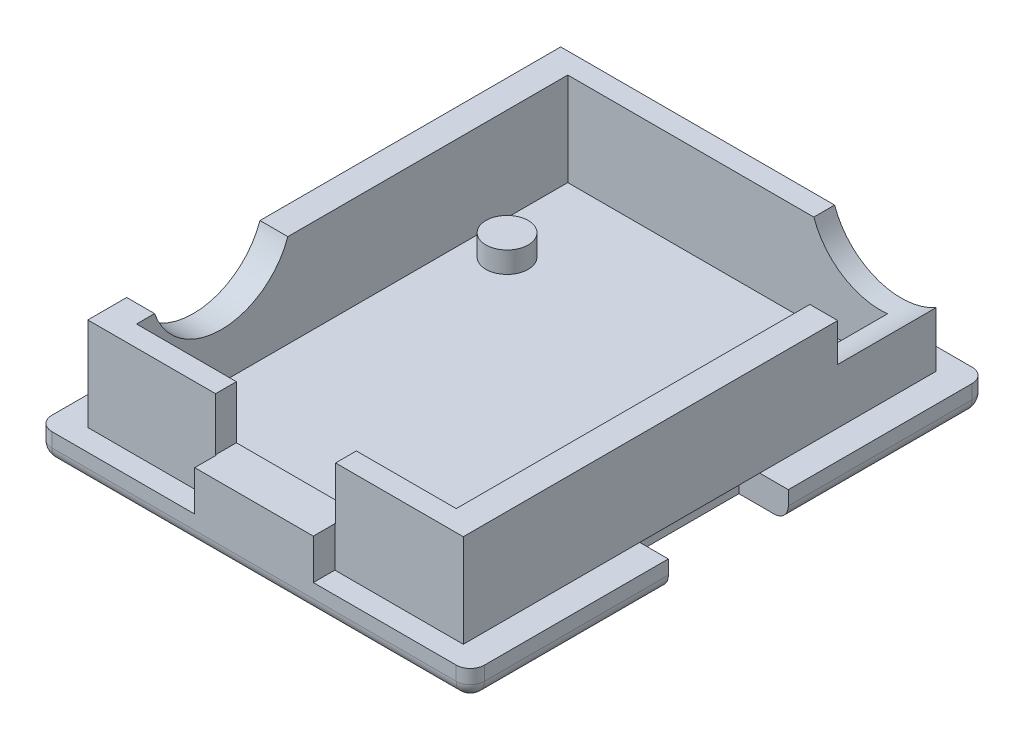
from build123d import *

# Parameters (mm, degrees)
SKETCH1_R               = 1
BOSS_EXTRUDE1_DEPTH     = 1.6
BOSS_EXTRUDE1_2_DEPTH   = 1.6
BOSS_EXTRUDE1_3_DEPTH   = 1.6
BOSS_EXTRUDE1_4_DEPTH   = 1.6
SKETCH2_R               = 1.5
BOSS_EXTRUDE2_DEPTH     = 1.5
BOSS_EXTRUDE3_DEPTH     = 2
SKETCH4_W               = 22.65
SKETCH4_H               = 30.55
BOSS_EXTRUDE4_DEPTH     = 6.6
SKETCH5_W               = 8.5
SKETCH5_H               = 3
CUT_EXTRUDE1_DEPTH      = 3.75
FILLET1_R               = 1
SKETCH6_R               = 5
CUT_EXTRUDE2_DEPTH      = 9
SKETCH8_R               = 5
CUT_EXTRUDE3_DEPTH      = 0.5
CUT_EXTRUDE3_DEPTH_BACK = 9
SKETCH9_W               = 22.65
SKETCH9_H               = 30.55
CUT_EXTRUDE4_DEPTH      = 1.6


with BuildPart() as part:
    # Sketch1 → Boss-Extrude1 (new body)
    with BuildSketch(Plane(origin=(0, 0.8, 0), x_dir=(1, 0, 0), z_dir=(0, 1, 0))):
        with Locations((-8.9, -13.05)):
            Circle(SKETCH1_R)
    extrude(amount=-BOSS_EXTRUDE1_DEPTH)



with BuildPart() as body_2:
    # Sketch1 → Boss-Extrude1 2 (new body)
    with BuildSketch(Plane(origin=(0, 0.8, 0), x_dir=(1, 0, 0), z_dir=(0, 1, 0))):
        with Locations((-8.9, 8.55)):
            Circle(SKETCH1_R)
    extrude(amount=-BOSS_EXTRUDE1_2_DEPTH)


with BuildPart() as body_3:
    # Sketch1 → Boss-Extrude1 3 (new body)
    with BuildSketch(Plane(origin=(0, 0.8, 0), x_dir=(1, 0, 0), z_dir=(0, 1, 0))):
        with Locations((8.9, 8.55)):
            Circle(SKETCH1_R)
    extrude(amount=-BOSS_EXTRUDE1_3_DEPTH)


with BuildPart() as body_4:
    # Sketch1 → Boss-Extrude1 4 (new body)
    with BuildSketch(Plane(origin=(0, 0.8, 0), x_dir=(1, 0, 0), z_dir=(0, 1, 0))):
        with Locations((8.9, -13.05)):
            Circle(SKETCH1_R)
    extrude(amount=-BOSS_EXTRUDE1_4_DEPTH)


with BuildPart() as part_1:
    add(part.part)

    add(body_2.part)  # Boss-Extrude2 merges body 2

    add(body_3.part)  # Boss-Extrude2 merges body 3

    add(body_4.part)  # Boss-Extrude2 merges body 4
    # Sketch2 → Boss-Extrude2 (add)
    with BuildSketch(Plane.XZ.offset(0.8)):
        with Locations((-8.9, -8.55)):
            Circle(SKETCH2_R)
        with Locations((-8.9, 13.05)):
            Circle(SKETCH2_R)
        with Locations((8.9, 13.05)):
            Circle(SKETCH2_R)
        with Locations((8.9, -8.55)):
            Circle(SKETCH2_R)
    extrude(amount=BOSS_EXTRUDE2_DEPTH)

    # Sketch3 → Boss-Extrude3 (add)
    with BuildSketch(Plane.XZ.offset(2.3)):
        Polygon((-15.325, 18.275), (15.325, 18.275), (15.325, 4.25), (11.825, 4.25), (11.825, -4.25), (15.325, -4.25), (15.325, -18.275), (-15.325, -18.275), (-15.325, -4.25), (-11.825, -4.25), (-11.825, 4.25), (-15.325, 4.25), align=None)
    extrude(amount=BOSS_EXTRUDE3_DEPTH)

    # Sketch4 → Boss-Extrude4 (add)
    with BuildSketch(Plane(origin=(0, -2.3, 0), x_dir=(1, 0, 0), z_dir=(0, 1, 0))):
        Polygon((-13.3, -16.75), (-4.2, -16.75), (-4.2, -18.275), (4.2, -18.275), (4.2, -16.75), (13.3, -16.75), (13.3, -4.5), (13.3, 4.5), (13.3, 16.75), (-13.3, 16.75), (-13.3, 4.5), (-13.3, -4.5), align=None)
        Rectangle(SKETCH4_W, SKETCH4_H, mode=Mode.SUBTRACT)
    extrude(amount=BOSS_EXTRUDE4_DEPTH)

    # Sketch5 → Cut-Extrude1 (cut)
    with BuildSketch(Plane(origin=(0, 4.3, 0), x_dir=(1, 0, 0), z_dir=(0, 1, 0))):
        with Locations((0, -16.775)):
            Rectangle(SKETCH5_W, SKETCH5_H)
    extrude(amount=-CUT_EXTRUDE1_DEPTH, mode=Mode.SUBTRACT)

    # Fillet1
    fillet1_edges = [part_1.edges().sort_by_distance(p)[0] for p in [
        (15.325, -3.3, 18.275),
        (-15.325, -3.3, 18.275),
        (-15.325, -3.3, -18.275),
        (15.325, -4.3, -11.2625),
        (15.325, -4.3, 11.2625),
        (0, -4.3, 18.275),
        (-15.325, -4.3, 11.2625),
        (-15.325, -4.3, -11.2625),
        (0, -4.3, -18.275),
        (15.325, -3.3, -18.275),
    ]]
    fillet(fillet1_edges, radius=FILLET1_R)

    # Sketch6 → Cut-Extrude2 (cut, through all)
    with BuildSketch(Plane(origin=(-7.325, 0, 0), x_dir=(0, 0, -1), z_dir=(1, 0, 0))):
        with Locations((-9.275, 5.95)):
            Circle(SKETCH6_R)
    extrude(amount=-CUT_EXTRUDE2_DEPTH, mode=Mode.SUBTRACT)

    # Sketch8 → Cut-Extrude3 (cut, two sides)
    with BuildSketch(Plane.XY.offset(-10.275)) as cut_extrude3_sk:
        with Locations((10.825, 5.95)):
            Circle(SKETCH8_R)
    extrude(amount=CUT_EXTRUDE3_DEPTH, mode=Mode.SUBTRACT)
    extrude(cut_extrude3_sk.sketch, amount=-CUT_EXTRUDE3_DEPTH_BACK, mode=Mode.SUBTRACT)

    # Sketch9 → Cut-Extrude4 (cut)
    with BuildSketch(Plane(origin=(0, 0.8, 0), x_dir=(1, 0, 0), z_dir=(0, 1, 0))):
        Rectangle(SKETCH9_W, SKETCH9_H)
    extrude(amount=-CUT_EXTRUDE4_DEPTH, mode=Mode.SUBTRACT)


solid = part_1.part
